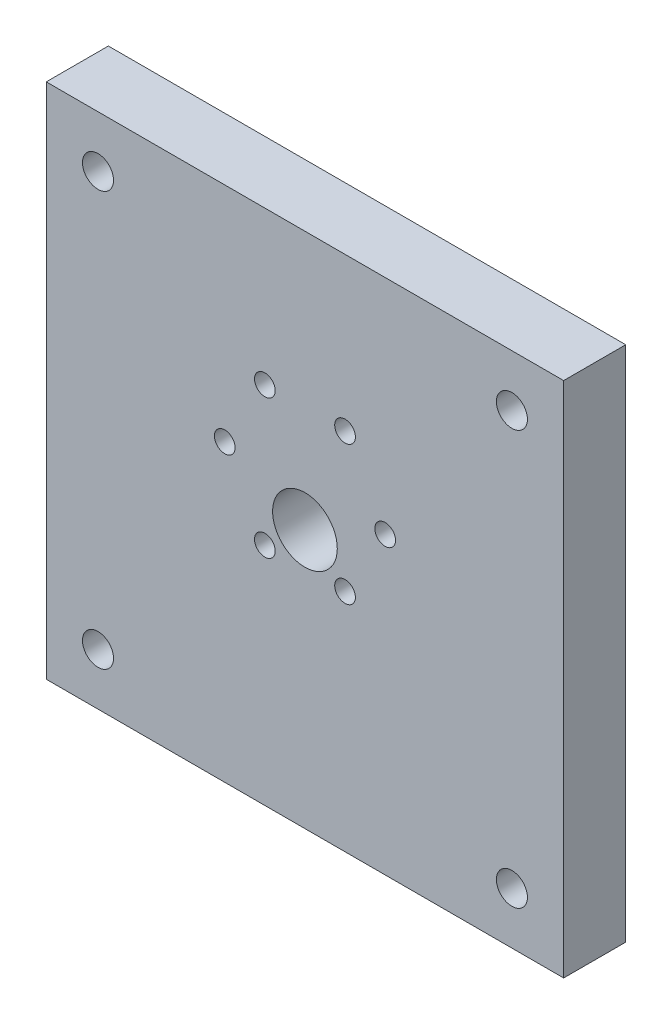
from build123d import *

# Parameters (mm, degrees)
ESQUISSE1_R             = 18.5
BOSS_EXTRU_1_DEPTH      = 12
ESQUISSE2_R             = 2
ENL_V_MAT_EXTRU_1_DEPTH = 13
ESQUISSE3_R             = 6.25
ENL_V_MAT_EXTRU_2_DEPTH = 13
ESQUISSE4_W             = 100
ESQUISSE4_H             = 100
ESQUISSE4_R             = 18.5
BOSS_EXTRU_2_DEPTH      = 12
ESQUISSE5_R             = 3
ENL_V_MAT_EXTRU_3_DEPTH = 12


with BuildPart() as part:
    # Esquisse1 → Boss.-Extru.1 (new body)
    with BuildSketch(Plane.XY):
        Circle(ESQUISSE1_R)
    extrude(amount=BOSS_EXTRU_1_DEPTH)

    # Esquisse2 → Enlèv. mat.-Extru.1 (cut, through all)
    with BuildSketch(Plane.XY.offset(12)):
        with Locations((15.5, 0)):
            Circle(ESQUISSE2_R)
        with Locations((7.75, -13.423393759)):
            Circle(ESQUISSE2_R)
        with Locations((-7.75, -13.423393759)):
            Circle(ESQUISSE2_R)
        with Locations((-15.5, 0)):
            Circle(ESQUISSE2_R)
        with Locations((-7.75, 13.423393759)):
            Circle(ESQUISSE2_R)
        with Locations((7.75, 13.423393759)):
            Circle(ESQUISSE2_R)
    extrude(amount=-ENL_V_MAT_EXTRU_1_DEPTH, mode=Mode.SUBTRACT)

    # Esquisse3 → Enlèv. mat.-Extru.2 (cut, through all)
    with BuildSketch(Plane.XY.offset(12)):
        with Locations((0, -7)):
            Circle(ESQUISSE3_R)
    extrude(amount=-ENL_V_MAT_EXTRU_2_DEPTH, mode=Mode.SUBTRACT)

    # Esquisse4 → Boss.-Extru.2 (add)
    with BuildSketch(Plane.XY.offset(12)):
        with Locations((0, -7)):
            Rectangle(ESQUISSE4_W, ESQUISSE4_H)
        Circle(ESQUISSE4_R, mode=Mode.SUBTRACT)
    extrude(amount=-BOSS_EXTRU_2_DEPTH)

    # Esquisse5 → Enlèv. mat.-Extru.3 (cut)
    with BuildSketch(Plane.XY.offset(12)):
        with Locations((-40, 33)):
            Circle(ESQUISSE5_R)
        with Locations((40, 33)):
            Circle(ESQUISSE5_R)
        with Locations((40, -47)):
            Circle(ESQUISSE5_R)
        with Locations((-40, -47)):
            Circle(ESQUISSE5_R)
    extrude(amount=-ENL_V_MAT_EXTRU_3_DEPTH, mode=Mode.SUBTRACT)


solid = part.part
